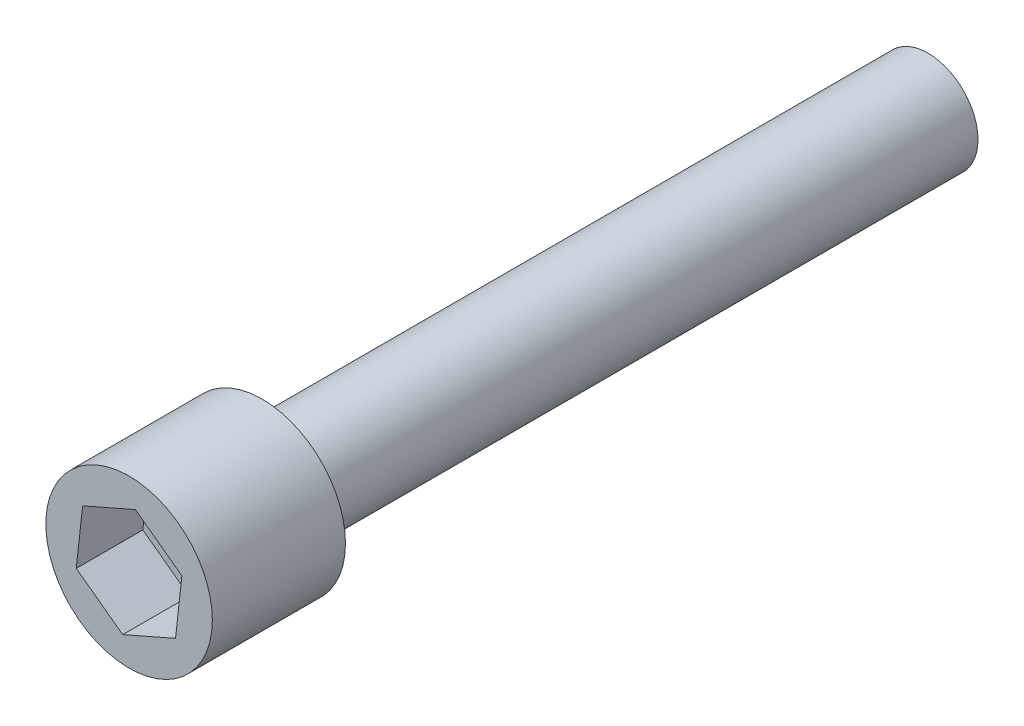
from build123d import *

# Parameters (mm, degrees)
SZKIC1_R                    = 5
DODANIE_WYCI_GNI_CIE1_DEPTH = 8
SZKIC2_R                    = 3
DODANIE_WYCI_GNI_CIE2_DEPTH = 40
WYTNIJ_WYCI_GNI_CIE1_DEPTH  = 4


with BuildPart() as part:
    # Szkic1 → Dodanie-wyciągnięcie1 (new body)
    with BuildSketch(Plane.XY):
        Circle(SZKIC1_R)
    extrude(amount=DODANIE_WYCI_GNI_CIE1_DEPTH)

    # Szkic2 → Dodanie-wyciągnięcie2 (add)
    with BuildSketch(Plane.XY):
        Circle(SZKIC2_R)
    extrude(amount=-DODANIE_WYCI_GNI_CIE2_DEPTH)

    # Szkic3 → Wytnij-wyciągnięcie1 (cut)
    with BuildSketch(Plane.XY.offset(8)):
        Polygon((2.791473495, -2.051261985), (3.172181736, 1.391855968), (0.380708241, 3.443117953), (-2.791473495, 2.051261985), (-3.172181736, -1.391855968), (-0.380708241, -3.443117953), align=None)
    extrude(amount=-WYTNIJ_WYCI_GNI_CIE1_DEPTH, mode=Mode.SUBTRACT)


solid = part.part
